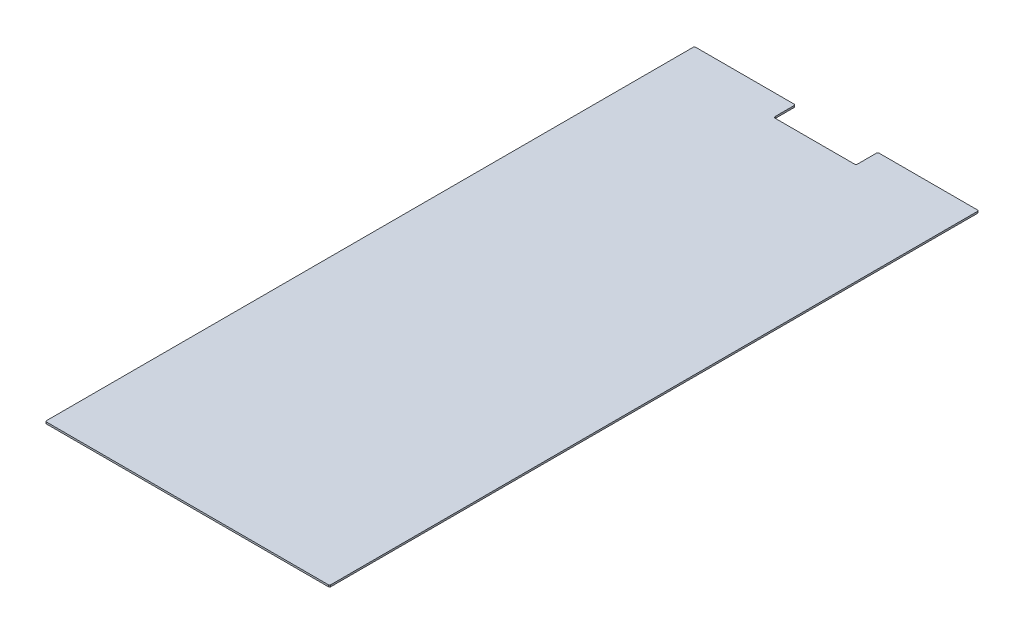
from build123d import *

# Parameters (mm, degrees)
BOSS_EXTRUDE1_DEPTH = 3


with BuildPart() as part:
    # Sketch2 → Boss-Extrude1 (new body)
    with BuildSketch(Plane(origin=(0, 0, 0), x_dir=(1, 0, 0), z_dir=(0, 1, 0))):
        with BuildLine():
            Line((-239.5, -551.5), (239.5, -551.5))
            ThreePointArc((239.5, -551.5), (240.914213562, -550.914213562), (241.5, -549.5))
            Line((241.5, -549.5), (241.5, 549.5))
            ThreePointArc((241.5, 549.5), (240.914213562, 550.914213562), (239.5, 551.5))
            Line((239.5, 551.5), (72, 551.5))
            ThreePointArc((72, 551.5), (70.585786438, 550.914213562), (70, 549.5))
            Line((70, 549.5), (70, 517.5))
            ThreePointArc((70, 517.5), (69.121320344, 515.378679656), (67, 514.5))
            Line((67, 514.5), (-67, 514.5))
            ThreePointArc((-67, 514.5), (-69.121320344, 515.378679656), (-70, 517.5))
            Line((-70, 517.5), (-70, 549.5))
            ThreePointArc((-70, 549.5), (-70.585786438, 550.914213562), (-72, 551.5))
            Line((-72, 551.5), (-239.5, 551.5))
            ThreePointArc((-239.5, 551.5), (-240.914213562, 550.914213562), (-241.5, 549.5))
            Line((-241.5, 549.5), (-241.5, -549.5))
            ThreePointArc((-241.5, -549.5), (-240.914213562, -550.914213562), (-239.5, -551.5))
        make_face()
    extrude(amount=BOSS_EXTRUDE1_DEPTH)


solid = part.part
